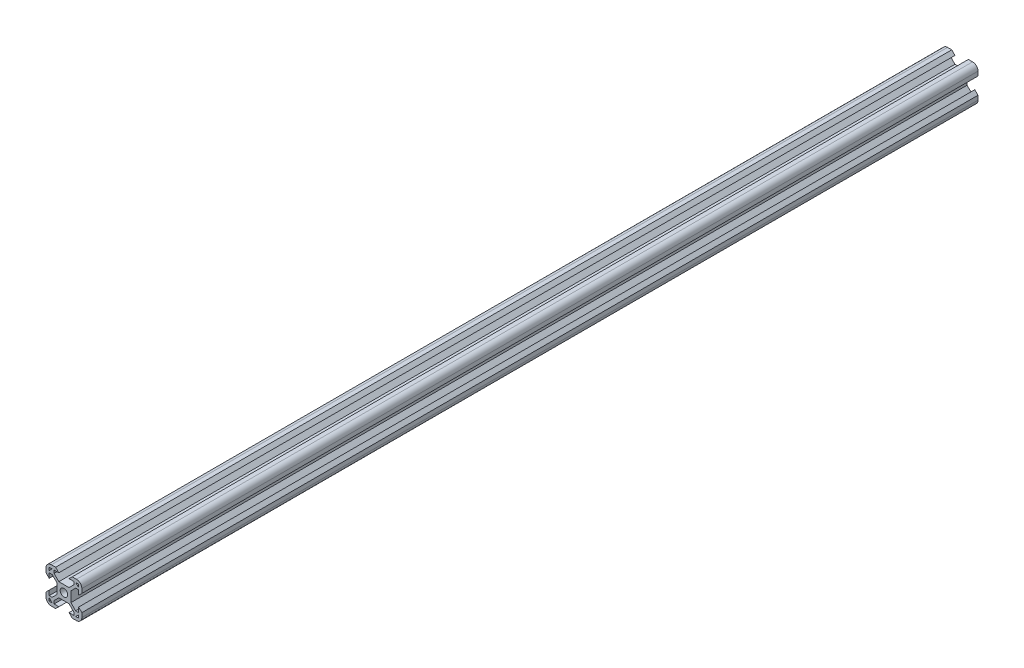
from build123d import *

# Parameters (mm, degrees)
SKETCH1_W           = 20
SKETCH1_H           = 20
BOSS_EXTRUDE1_DEPTH = 500
CUT_EXTRUDE2_REACH  = 502.2
CIRPATTERN1_COUNT   = 4
CUT_EXTRUDE3_REACH  = 502.2
SKETCH3_R           = 2.1
CUT_EXTRUDE4_REACH  = 502.2
CIRPATTERN2_COUNT   = 4
FILLET1_R           = 3


with BuildPart() as part:
    # Sketch1 → Boss-Extrude1 (new body)
    with BuildSketch(Plane.XY):
        Rectangle(SKETCH1_W, SKETCH1_H)
    extrude(amount=-BOSS_EXTRUDE1_DEPTH)

    # Sketch2 → Cut-Extrude2 (cut, up to next)
    with BuildSketch(Plane.XY, mode=Mode.PRIVATE) as cut_extrude2_sk1:
        Polygon((-5.499339828, -6.56), (-2.84, -3.900660172), (2.84, -3.900660172), (5.499339828, -6.56), (5.499339828, -8.2), (2.84, -8.2), (4.64, -10), (-4.64, -10), (-2.84, -8.2), (-5.499339828, -8.2), align=None)
    cut_extrude2_tool1 = extrude(cut_extrude2_sk1.sketch, amount=-CUT_EXTRUDE2_REACH, mode=Mode.PRIVATE) & part.part
    cut_extrude2 = cut_extrude2_tool1.solids().sort_by_distance((0, -6.999797, 0))[0]
    add(cut_extrude2, mode=Mode.SUBTRACT)

    # CirPattern1: Cut-Extrude2 ×4 about axis
    cirpattern1_axis = Axis((0, 0, -525), (0, 0, 1))
    for i in range(1, CIRPATTERN1_COUNT):
        add(cut_extrude2.rotate(cirpattern1_axis, i * 360 / CIRPATTERN1_COUNT), mode=Mode.SUBTRACT)

    # Sketch3 → Cut-Extrude3 (cut, up to next)
    with BuildSketch(Plane.XY, mode=Mode.PRIVATE) as cut_extrude3_sk1:
        Circle(SKETCH3_R)
    cut_extrude3_tool1 = extrude(cut_extrude3_sk1.sketch, amount=-CUT_EXTRUDE3_REACH, mode=Mode.PRIVATE) & part.part
    add(cut_extrude3_tool1.solids().sort_by_distance((0, 0, 0))[0], mode=Mode.SUBTRACT)

    # Sketch4 → Cut-Extrude4 (cut, up to next)
    with BuildSketch(Plane.XY, mode=Mode.PRIVATE) as cut_extrude4_sk1:
        Polygon((-8.2, 8.2), (-8.2, 6.569339828), (-6.569339828, 8.2), align=None)
    cut_extrude4_tool1 = extrude(cut_extrude4_sk1.sketch, amount=-CUT_EXTRUDE4_REACH, mode=Mode.PRIVATE) & part.part
    cut_extrude4 = cut_extrude4_tool1.solids().sort_by_distance((-7.656447, 7.656447, 0))[0]
    add(cut_extrude4, mode=Mode.SUBTRACT)

    # CirPattern2: Cut-Extrude4 ×4 about axis
    cirpattern2_axis = Axis((0, 0, -525), (0, 0, 1))
    for i in range(1, CIRPATTERN2_COUNT):
        add(cut_extrude4.rotate(cirpattern2_axis, i * 360 / CIRPATTERN2_COUNT), mode=Mode.SUBTRACT)

    # Fillet1
    fillet1_edges = [part.edges().sort_by_distance(p)[0] for p in [
        (-10, -10, -250),
        (-10, 10, -250),
        (10, 10, -250),
        (10, -10, -250),
    ]]
    fillet(fillet1_edges, radius=FILLET1_R)


solid = part.part
